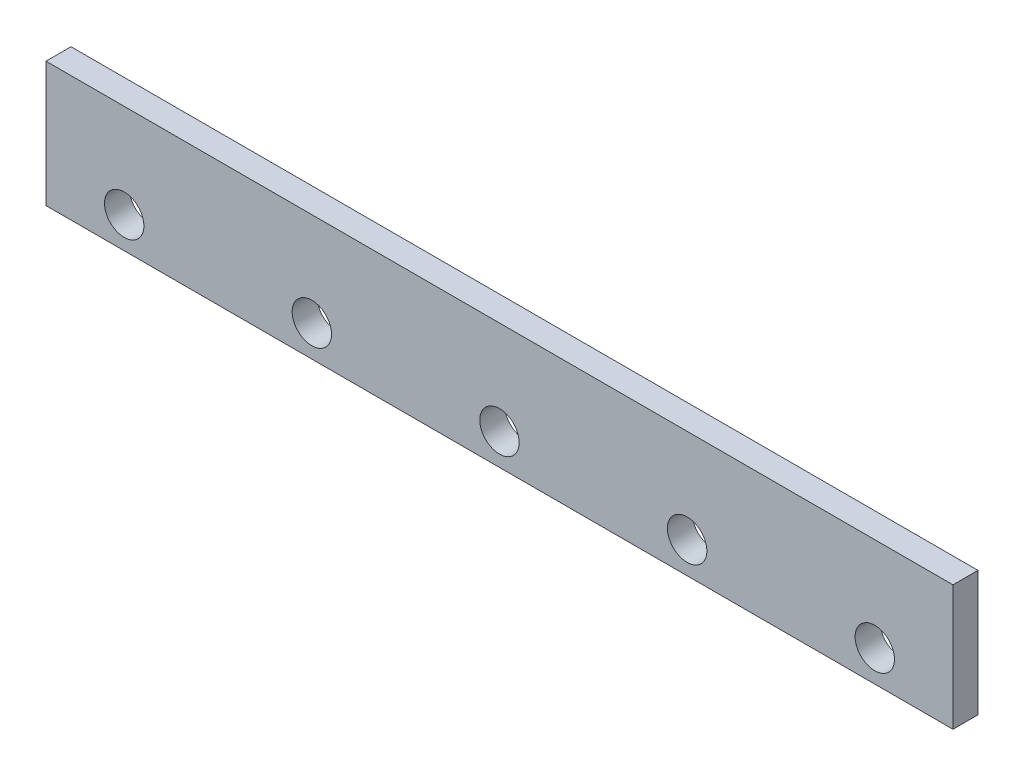
from build123d import *

# Parameters (mm, degrees)
SKETCH1_W           = 580
SKETCH1_H           = 80
BOSS_EXTRUDE1_DEPTH = 16
SKETCH2_R           = 12.6
CUT_EXTRUDE1_DEPTH  = 16


with BuildPart() as part:
    # Sketch1 → Boss-Extrude1 (new body)
    with BuildSketch(Plane.XY):
        Rectangle(SKETCH1_W, SKETCH1_H)
    extrude(amount=BOSS_EXTRUDE1_DEPTH)

    # Sketch2 → Cut-Extrude1 (cut)
    with BuildSketch(Plane.XY.offset(16)):
        with Locations((-240, -20)):
            Circle(SKETCH2_R)
        with Locations((-120, -20)):
            Circle(SKETCH2_R)
        with Locations((0, -20)):
            Circle(SKETCH2_R)
        with Locations((120, -20)):
            Circle(SKETCH2_R)
        with Locations((240, -20)):
            Circle(SKETCH2_R)
    extrude(amount=-CUT_EXTRUDE1_DEPTH, mode=Mode.SUBTRACT)


solid = part.part
